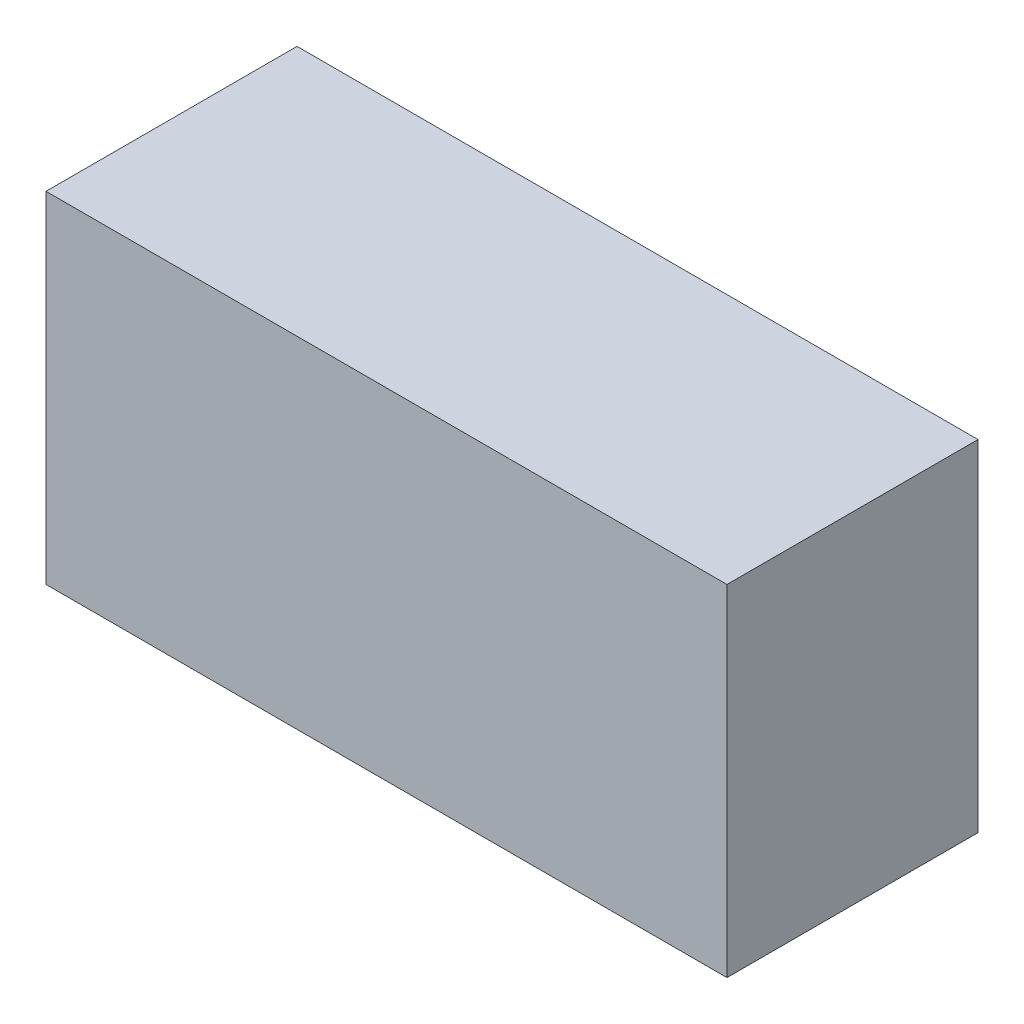
from build123d import *

# Parameters (mm, degrees)
SKETCH1_W           = 59.944
SKETCH1_H           = 29.972
BOSS_EXTRUDE1_DEPTH = 22.098


with BuildPart() as part:
    # Sketch1 → Boss-Extrude1 (new body)
    with BuildSketch(Plane.XY):
        Rectangle(SKETCH1_W, SKETCH1_H)
    extrude(amount=BOSS_EXTRUDE1_DEPTH)


solid = part.part
